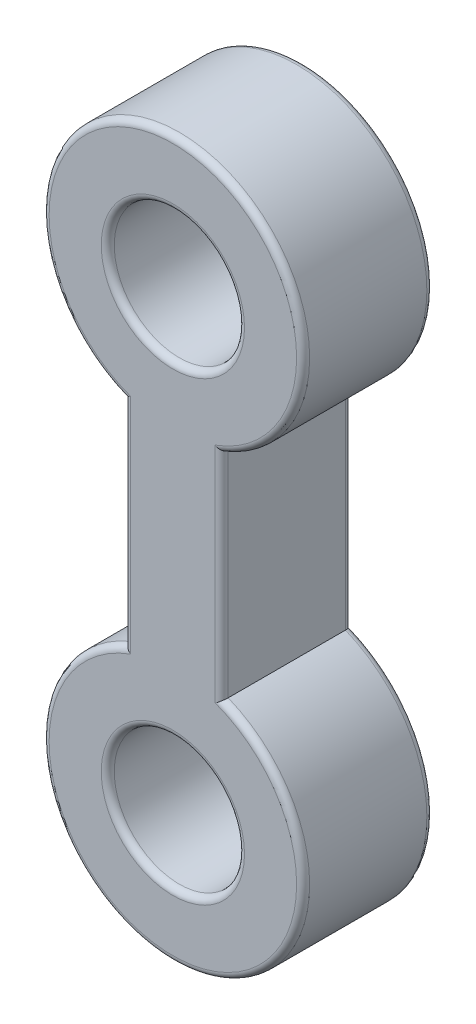
from build123d import *

# Parameters (mm, degrees)
SKETCH1_R           = 10
BOSS_EXTRUDE1_DEPTH = 10
FILLET1_R           = 1


with BuildPart() as part:
    # Sketch1 → Boss-Extrude1 (new body, symmetric)
    with BuildSketch(Plane.XY):
        with BuildLine():
            Line((-7.5, -18.540496218), (-7.5, -51.459503782))
            ThreePointArc((-7.5, -51.459503782), (0, -90), (7.5, -51.459503782))
            Line((7.5, -51.459503782), (7.5, -18.540496218))
            ThreePointArc((7.5, -18.540496218), (0, 20), (-7.5, -18.540496218))
        make_face()
        Circle(SKETCH1_R, mode=Mode.SUBTRACT)
        with Locations((0, -70)):
            Circle(SKETCH1_R, mode=Mode.SUBTRACT)
    extrude(amount=BOSS_EXTRUDE1_DEPTH, both=True)

    # Fillet1
    fillet1_edges = [part.edges().sort_by_distance(p)[0] for p in [
        (-10, 0, -10),
        (-10, 0, 10),
        (0, -90, 10),
        (-10, -70, -10),
        (-10, -70, 10),
        (7.5, -35, 10),
        (0, 20, 10),
        (7.5, -35, -10),
        (0, -90, -10),
        (-7.5, -35, -10),
        (0, 20, -10),
        (-7.5, -35, 10),
    ]]
    fillet(fillet1_edges, radius=FILLET1_R)


solid = part.part
